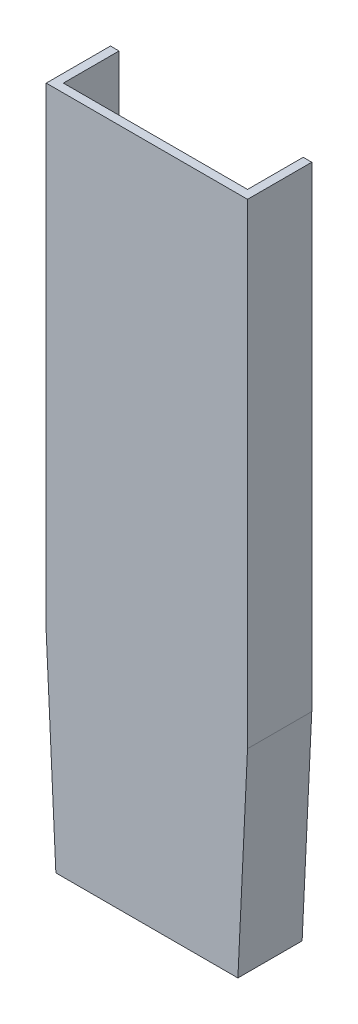
from build123d import *

# Parameters (mm, degrees)
DODANIE_WYCI_GNI_CIE1_DEPTH = 30
SKORUPA2_T                  = -4


with BuildPart() as part:
    # Szkic1 → Dodanie-wyciągnięcie1 (new body)
    with BuildSketch(Plane.XY):
        Polygon((-43.89930842, 241.108747994), (50.10069158, 241.108747994), (50.10069158, 18.932504013), (45.60069158, -76.067495987), (-39.39930842, -76.067495987), (-43.89930842, 18.932504013), align=None)
    extrude(amount=DODANIE_WYCI_GNI_CIE1_DEPTH)

    # Skorupa2
    skorupa2_openings = [part.faces().sort_by_distance(p)[0] for p in [
        (3.10069158, 241.108747994, 15),
        (3.10069158, -76.067495987, 15),
        (3.10069158, 84.366979784, 0),
    ]]
    offset(amount=SKORUPA2_T, openings=skorupa2_openings, kind=Kind.INTERSECTION)


solid = part.part
